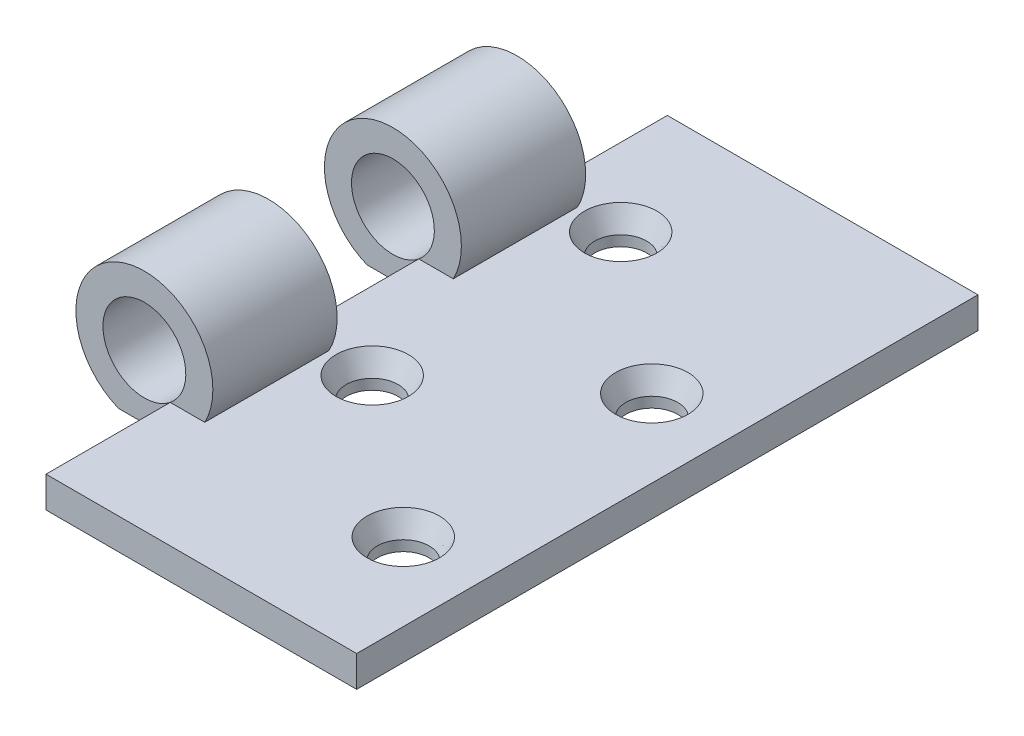
from build123d import *

# Parameters (mm, degrees)
SKETCH1_W           = 30
SKETCH1_H           = 60
BOSS_EXTRUDE1_DEPTH = 3
BOSS_EXTRUDE2_START = -12
SKETCH2_R           = 4
BOSS_EXTRUDE2_DEPTH = 12
SKETCH8_R           = 2.5
CUT_EXTRUDE1_DEPTH  = 4
CHAMFER1_SIZE       = 1
CHAMFER1_SIZE2      = 2


with BuildPart() as part:
    # Sketch1 → Boss-Extrude1 (new body)
    with BuildSketch(Plane(origin=(0, 0, 0), x_dir=(1, 0, 0), z_dir=(0, 1, 0))):
        Rectangle(SKETCH1_W, SKETCH1_H)
    extrude(amount=BOSS_EXTRUDE1_DEPTH)

    # Sketch2 → Boss-Extrude2 (add)
    with BuildSketch(Plane.XY.offset(30).offset(BOSS_EXTRUDE2_START)):
        with BuildLine():
            Line((-15, 0), (-20, 0))
            ThreePointArc((-20, 0), (-17.5, 12.735742832), (-15, 0))
        make_face()
        with Locations((-17.5, 6.122498999)):
            Circle(SKETCH2_R, mode=Mode.SUBTRACT)
    boss_extrude2 = extrude(amount=-BOSS_EXTRUDE2_DEPTH)

    # Mirror1: Boss-Extrude2 across plane
    add(boss_extrude2.mirror(Plane.XY))

    # Sketch8 → Cut-Extrude1 (cut, through all)
    with BuildSketch(Plane(origin=(0, 3, 0), x_dir=(1, 0, 0), z_dir=(0, 1, 0))):
        with Locations((7.5, -18)):
            Circle(SKETCH8_R)
        with Locations((-7.5, -6)):
            Circle(SKETCH8_R)
        with Locations((7.5, 6)):
            Circle(SKETCH8_R)
        with Locations((-7.5, 18)):
            Circle(SKETCH8_R)
    extrude(amount=-CUT_EXTRUDE1_DEPTH, mode=Mode.SUBTRACT)

    # Chamfer1
    chamfer1_edges = [part.edges().sort_by_distance(p)[0] for p in [
        (-10, 3, -18),
        (-10, 3, 6),
        (5, 3, 18),
        (5, 3, -6),
    ]]
    chamfer1_side = [part.faces().sort_by_distance(p)[0] for p in [
        (0.649167265, 3, 0),
    ]]
    chamfer(chamfer1_edges, length=CHAMFER1_SIZE, length2=CHAMFER1_SIZE2, reference=chamfer1_side[0])


solid = part.part
